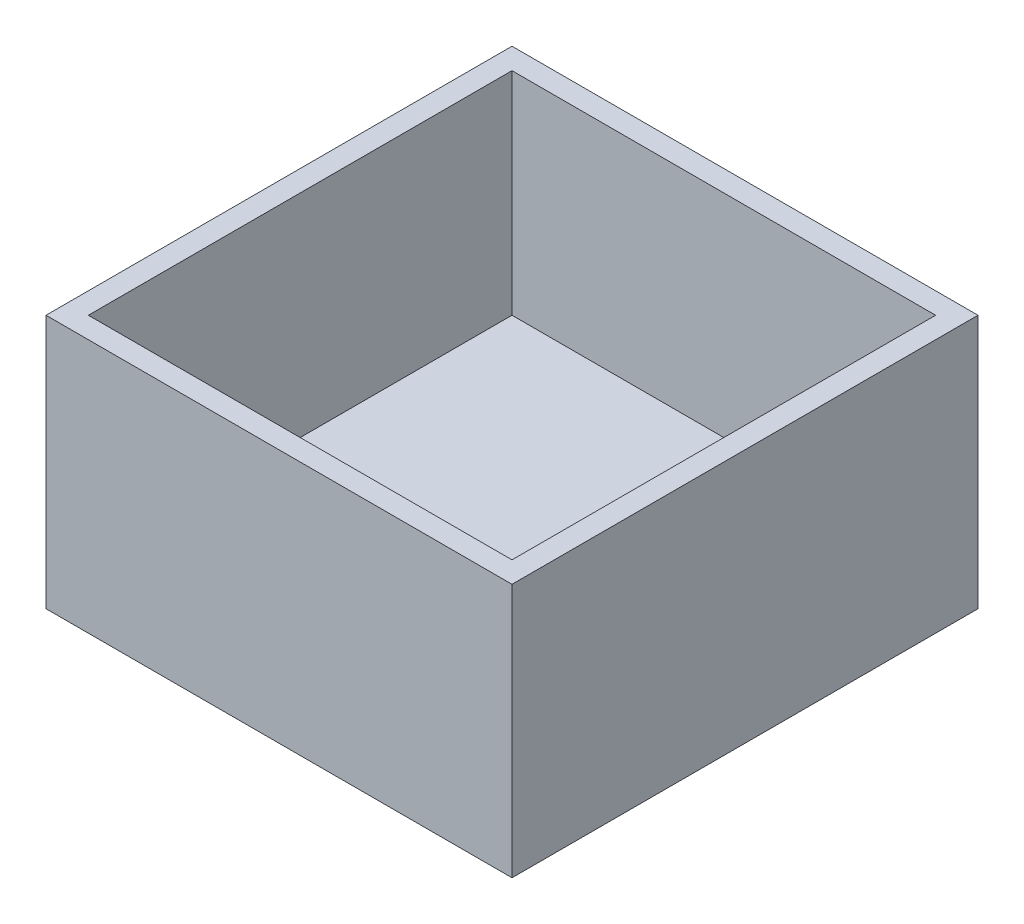
from build123d import *

# Parameters (mm, degrees)
SKETCH2_W           = 22
SKETCH2_H           = 22
SKETCH2_W_2         = 20
SKETCH2_H_2         = 20
BOSS_EXTRUDE1_DEPTH = 12
SKETCH3_W           = 20
SKETCH3_H           = 20
BOSS_EXTRUDE2_DEPTH = 2


with BuildPart() as part:
    # Sketch2 → Boss-Extrude1 (new body)
    with BuildSketch(Plane(origin=(0, 0, 0), x_dir=(1, 0, 0), z_dir=(0, 1, 0))):
        Rectangle(SKETCH2_W, SKETCH2_H)
        Rectangle(SKETCH2_W_2, SKETCH2_H_2, mode=Mode.SUBTRACT)
    extrude(amount=BOSS_EXTRUDE1_DEPTH)

    # Sketch3 → Boss-Extrude2 (add)
    with BuildSketch(Plane(origin=(0, 0, 0), x_dir=(1, 0, 0), z_dir=(0, 1, 0))):
        Rectangle(SKETCH3_W, SKETCH3_H)
    extrude(amount=BOSS_EXTRUDE2_DEPTH)


solid = part.part
